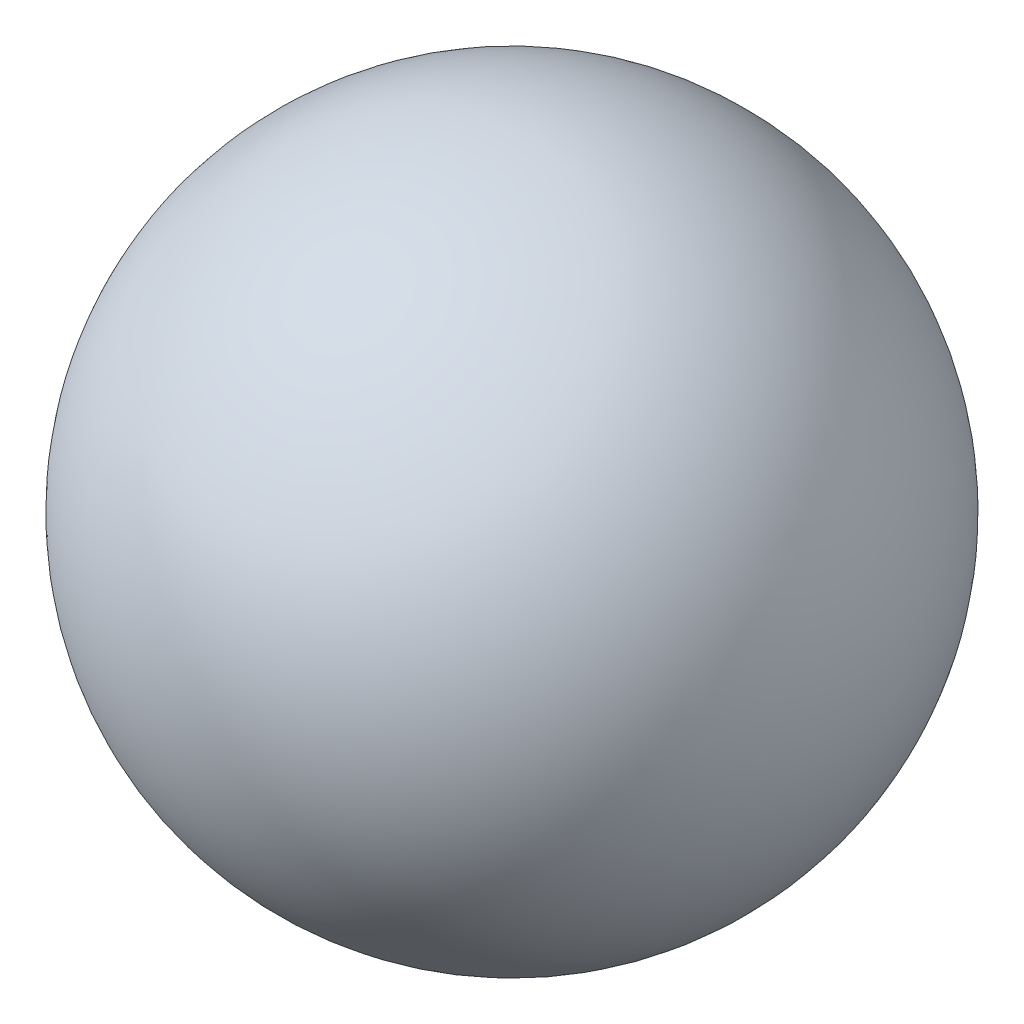
from build123d import *


with BuildPart() as part:
    # Sketch1 → Revolve1 (revolve)
    with BuildSketch(Plane.XY):
        with BuildLine():
            Line((-6.275, 0), (6.275, 0))
            ThreePointArc((6.275, 0), (0, 6.275), (-6.275, 0))
        make_face()
    revolve(axis=Axis((-6.275, 0, 0), (1, 0, 0)))


solid = part.part
